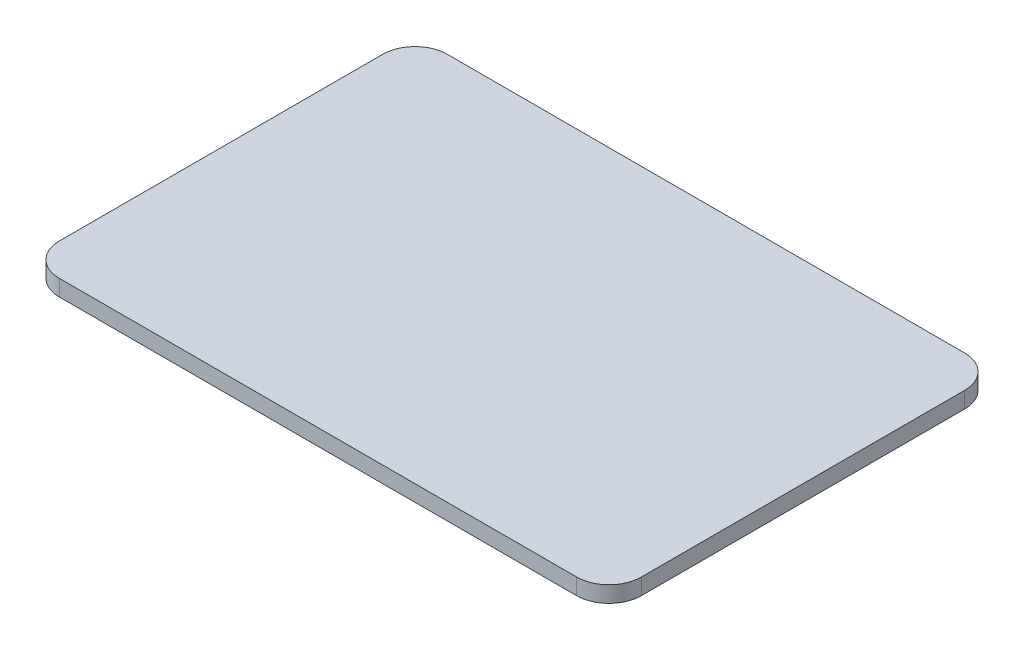
from build123d import *

# Parameters (mm, degrees)
SKETCH1_W           = 180
SKETCH1_H           = 120
BOSS_EXTRUDE1_DEPTH = 5
FILLET1_R           = 10
FILLET2_R           = 10
FILLET3_R           = 10
FILLET4_R           = 10


with BuildPart() as part:
    # Sketch1 → Boss-Extrude1 (new body)
    with BuildSketch(Plane(origin=(0, 0, 0), x_dir=(1, 0, 0), z_dir=(0, 1, 0))):
        Rectangle(SKETCH1_W, SKETCH1_H)
    extrude(amount=BOSS_EXTRUDE1_DEPTH)

    # Fillet1
    fillet1_edges = [part.edges().sort_by_distance(p)[0] for p in [
        (-90, 2.5, -60),
    ]]
    fillet(fillet1_edges, radius=FILLET1_R)

    # Fillet2
    fillet2_edges = [part.edges().sort_by_distance(p)[0] for p in [
        (-90, 2.5, 60),
    ]]
    fillet(fillet2_edges, radius=FILLET2_R)

    # Fillet3
    fillet3_edges = [part.edges().sort_by_distance(p)[0] for p in [
        (90, 2.5, 60),
    ]]
    fillet(fillet3_edges, radius=FILLET3_R)

    # Fillet4
    fillet4_edges = [part.edges().sort_by_distance(p)[0] for p in [
        (90, 2.5, -60),
    ]]
    fillet(fillet4_edges, radius=FILLET4_R)


solid = part.part
